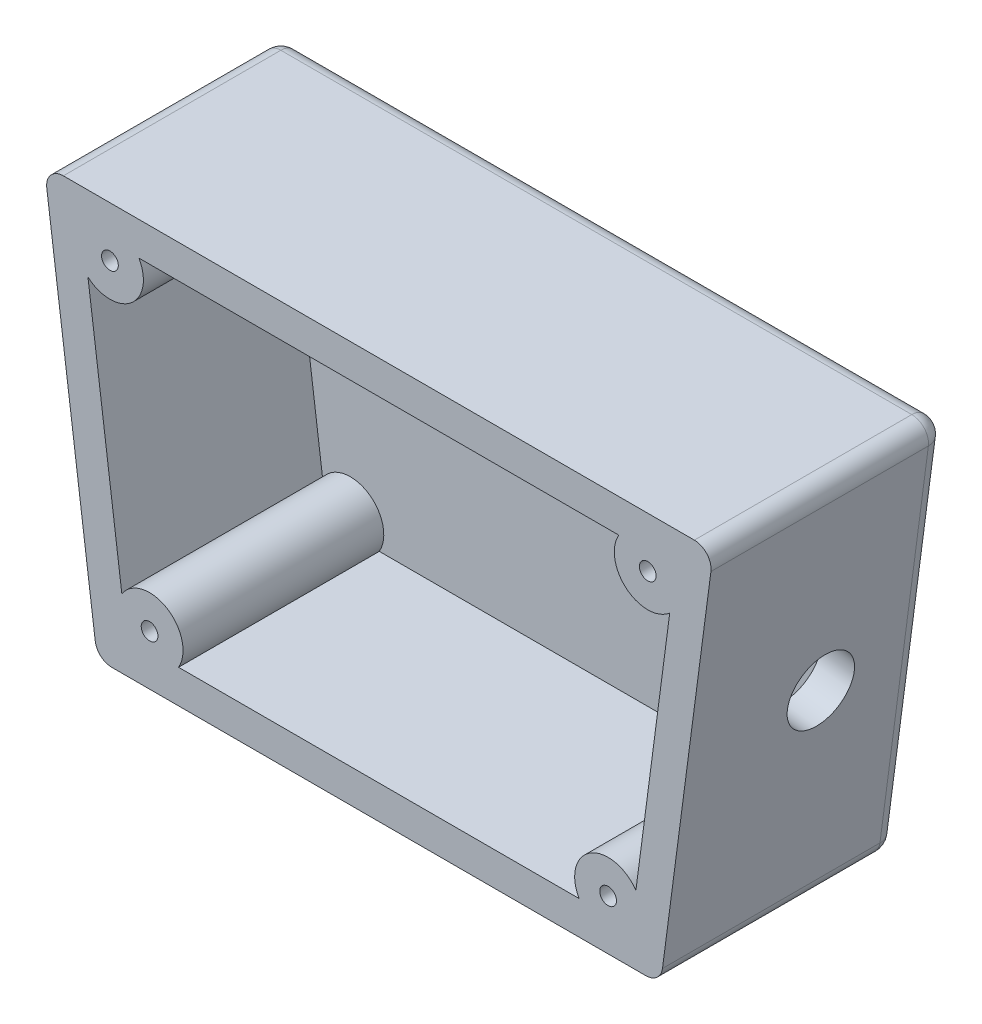
from build123d import *

# Parameters (mm, degrees)
BOSS_EXTRUDE1_DEPTH      = 3.175
BOSS_EXTRUDE2_DEPTH      = 3.175
SKETCH2_R                = 3.175
BOSS_EXTRUDE3_DEPTH      = 6.35
BOSS_EXTRUDE4_DEPTH      = 12.7
SKETCH2_4_R              = 3.175
CUT_EXTRUDE1_DEPTH       = 76.134213245
CUT_EXTRUDE1_DEPTH_BACK  = 76.134213245
FILLET1_R                = 6.35
SKETCH4_R                = 3.175
BOSS_EXTRUDE5_DEPTH      = 6.35
SKETCH4_2_R              = 3.175
CUT_EXTRUDE2_DEPTH       = 76.134213245
CUT_EXTRUDE2_DEPTH_BACK  = 76.134213245
BOSS_EXTRUDE6_DEPTH      = 38.1
BOSS_EXTRUDE7_START      = -38.1
BOSS_EXTRUDE7_DEPTH      = 6.35
BOSS_EXTRUDE11_REACH     = 88.369
SKETCH5_R                = 1.5875
SKETCH5_4_R              = 1.5875
CUT_EXTRUDE9_DEPTH       = 87.36933773
CUT_EXTRUDE9_DEPTH_BACK  = 87.36933773
SKETCH6_R                = 6.35
CUT_EXTRUDE10_DEPTH      = 6.35
CUT_EXTRUDE10_DEPTH_BACK = 510.682305539
CHAMFER1_SIZE            = 2.54
FILLET2_R                = 3.175
FILLET3_R                = 3.175


with BuildPart() as part:
    # Sketch1 → Boss-Extrude1 (new body)
    with BuildSketch(Plane.XY):
        Polygon((-53.468079684, -38.1), (53.468079684, -38.1), (63.5, 38.1), (-63.5, 38.1), align=None)
        Polygon((47.899279144, -31.75), (56.259212741, 31.75), (-56.259212741, 31.75), (-47.899279144, -31.75), align=None, mode=Mode.SUBTRACT)
        Polygon((-47.899279144, -31.75), (47.899279144, -31.75), (56.259212741, 31.75), (-56.259212741, 31.75), align=None)
    extrude(amount=BOSS_EXTRUDE1_DEPTH)

    # Sketch1_3 → Boss-Extrude2 (add)
    with BuildSketch(Plane.XY):
        Polygon((-47.899279144, -31.75), (47.899279144, -31.75), (56.259212741, 31.75), (-56.259212741, 31.75), align=None)
    extrude(amount=-BOSS_EXTRUDE2_DEPTH)

    # Sketch2 → Boss-Extrude3 (add)
    with BuildSketch(Plane.XY):
        with BuildLine():
            ThreePointArc((-37.837241379, 27.272155172), (-39.021250412, 27.544911403), (-39.665603448, 28.575))
            Line((-39.665603448, 28.575), (-39.665603448, 15.875))
            Line((-39.665603448, 15.875), (39.665603448, 15.875))
            Line((39.665603448, 15.875), (39.665603448, 28.575))
            ThreePointArc((39.665603448, 28.575), (39.021250412, 27.544911403), (37.837241379, 27.272155172))
            ThreePointArc((37.837241379, 27.272155172), (0, 30.425258621), (-37.837241379, 27.272155172))
        make_face()
        with Locations((-33.3375, 22.225)):
            Circle(SKETCH2_R, mode=Mode.SUBTRACT)
        with Locations((-23.8125, 22.225)):
            Circle(SKETCH2_R, mode=Mode.SUBTRACT)
        with Locations((-14.2875, 22.225)):
            Circle(SKETCH2_R, mode=Mode.SUBTRACT)
        with Locations((-4.7625, 22.225)):
            Circle(SKETCH2_R, mode=Mode.SUBTRACT)
        with Locations((4.7625, 22.225)):
            Circle(SKETCH2_R, mode=Mode.SUBTRACT)
        with Locations((14.2875, 22.225)):
            Circle(SKETCH2_R, mode=Mode.SUBTRACT)
        with Locations((23.8125, 22.225)):
            Circle(SKETCH2_R, mode=Mode.SUBTRACT)
        with Locations((33.3375, 22.225)):
            Circle(SKETCH2_R, mode=Mode.SUBTRACT)
        with Locations((-33.3375, 22.225)):
            Circle(SKETCH2_R)
        with Locations((-23.8125, 22.225)):
            Circle(SKETCH2_R)
        with Locations((-14.2875, 22.225)):
            Circle(SKETCH2_R)
        with Locations((-4.7625, 22.225)):
            Circle(SKETCH2_R)
        with Locations((4.7625, 22.225)):
            Circle(SKETCH2_R)
        with Locations((14.2875, 22.225)):
            Circle(SKETCH2_R)
        with Locations((23.8125, 22.225)):
            Circle(SKETCH2_R)
        with Locations((33.3375, 22.225)):
            Circle(SKETCH2_R)
        with BuildLine():
            ThreePointArc((-37.837241379, 27.272155172), (0, 30.425258621), (37.837241379, 27.272155172))
            ThreePointArc((37.837241379, 27.272155172), (39.665603448, 28.575), (38.362758621, 30.403362069))
            ThreePointArc((38.362758621, 30.403362069), (0, 33.600258621), (-38.362758621, 30.403362069))
            ThreePointArc((-38.362758621, 30.403362069), (-39.665603448, 28.575), (-37.837241379, 27.272155172))
        make_face()
    extrude(amount=BOSS_EXTRUDE3_DEPTH)

    # Sketch2_3 → Boss-Extrude4 (add)
    with BuildSketch(Plane.XY):
        with BuildLine():
            ThreePointArc((-37.837241379, 27.272155172), (0, 30.425258621), (37.837241379, 27.272155172))
            ThreePointArc((37.837241379, 27.272155172), (39.665603448, 28.575), (38.362758621, 30.403362069))
            ThreePointArc((38.362758621, 30.403362069), (0, 33.600258621), (-38.362758621, 30.403362069))
            ThreePointArc((-38.362758621, 30.403362069), (-39.665603448, 28.575), (-37.837241379, 27.272155172))
        make_face()
    extrude(amount=BOSS_EXTRUDE4_DEPTH)

    # Sketch2_4 → Cut-Extrude1 (cut, two sides)
    with BuildSketch(Plane.XY) as cut_extrude1_sk:
        with Locations((-33.3375, 22.225)):
            Circle(SKETCH2_4_R)
        with Locations((-23.8125, 22.225)):
            Circle(SKETCH2_4_R)
        with Locations((-14.2875, 22.225)):
            Circle(SKETCH2_4_R)
        with Locations((-4.7625, 22.225)):
            Circle(SKETCH2_4_R)
        with Locations((4.7625, 22.225)):
            Circle(SKETCH2_4_R)
        with Locations((14.2875, 22.225)):
            Circle(SKETCH2_4_R)
        with Locations((23.8125, 22.225)):
            Circle(SKETCH2_4_R)
        with Locations((33.3375, 22.225)):
            Circle(SKETCH2_4_R)
    extrude(amount=CUT_EXTRUDE1_DEPTH, mode=Mode.SUBTRACT)
    extrude(cut_extrude1_sk.sketch, amount=-CUT_EXTRUDE1_DEPTH_BACK, mode=Mode.SUBTRACT)

    # Fillet1
    fillet1_edges = [part.edges().sort_by_distance(p)[0] for p in [
        (39.665603448, 15.875, 4.7625),
        (-39.665603448, 15.875, 4.7625),
    ]]
    fillet(fillet1_edges, radius=FILLET1_R)

    # Sketch4 → Boss-Extrude5 (add)
    with BuildSketch(Plane.XY):
        with BuildLine():
            Line((-26.965603448, 6.35), (-26.965603448, -19.05))
            ThreePointArc((-26.965603448, -19.05), (-33.315603448, -25.4), (-39.665603448, -19.05))
            Line((-39.665603448, -19.05), (-39.665603448, 6.35))
            ThreePointArc((-39.665603448, 6.35), (-33.315603448, 12.7), (-26.965603448, 6.35))
        make_face()
        with Locations((-33.315603448, 6.35)):
            Circle(SKETCH4_R, mode=Mode.SUBTRACT)
        with Locations((-33.315603448, -6.35)):
            Circle(SKETCH4_R, mode=Mode.SUBTRACT)
        with Locations((-33.315603448, -19.05)):
            Circle(SKETCH4_R, mode=Mode.SUBTRACT)
        with BuildLine():
            Line((39.665603448, 6.35), (39.665603448, -19.05))
            ThreePointArc((39.665603448, -19.05), (33.315603448, -25.4), (26.965603448, -19.05))
            Line((26.965603448, -19.05), (26.965603448, 6.35))
            ThreePointArc((26.965603448, 6.35), (33.315603448, 12.7), (39.665603448, 6.35))
        make_face()
        with Locations((33.315603448, 6.35)):
            Circle(SKETCH4_R, mode=Mode.SUBTRACT)
        with Locations((33.315603448, -6.35)):
            Circle(SKETCH4_R, mode=Mode.SUBTRACT)
        with Locations((33.315603448, -19.05)):
            Circle(SKETCH4_R, mode=Mode.SUBTRACT)
    extrude(amount=BOSS_EXTRUDE5_DEPTH)

    # Sketch4_2 → Cut-Extrude2 (cut, two sides)
    with BuildSketch(Plane.XY) as cut_extrude2_sk:
        with Locations((-33.315603448, 6.35)):
            Circle(SKETCH4_2_R)
        with Locations((-33.315603448, -6.35)):
            Circle(SKETCH4_2_R)
        with Locations((-33.315603448, -19.05)):
            Circle(SKETCH4_2_R)
        with Locations((33.315603448, -19.05)):
            Circle(SKETCH4_2_R)
        with Locations((33.315603448, -6.35)):
            Circle(SKETCH4_2_R)
        with Locations((33.315603448, 6.35)):
            Circle(SKETCH4_2_R)
    extrude(amount=CUT_EXTRUDE2_DEPTH, mode=Mode.SUBTRACT)
    extrude(cut_extrude2_sk.sketch, amount=-CUT_EXTRUDE2_DEPTH_BACK, mode=Mode.SUBTRACT)

    # Sketch5_4 → Cut-Extrude9 (cut, two sides)
    with BuildSketch(Plane.XY) as cut_extrude9_sk:
        with Locations((-51.037620636, 28.575)):
            Circle(SKETCH5_4_R)
        with Locations((-43.513680399, -28.575)):
            Circle(SKETCH5_4_R)
        with Locations((43.513680399, -28.575)):
            Circle(SKETCH5_4_R)
        with Locations((51.037620636, 28.575)):
            Circle(SKETCH5_4_R)
    extrude(amount=CUT_EXTRUDE9_DEPTH, mode=Mode.SUBTRACT)
    extrude(cut_extrude9_sk.sketch, amount=-CUT_EXTRUDE9_DEPTH_BACK, mode=Mode.SUBTRACT)

    # Chamfer1
    chamfer1_edges = [part.edges().sort_by_distance(p)[0] for p in [
        (-52.625120636, 28.575, 3.175),
        (-45.101180399, -28.575, 3.175),
        (41.926180399, -28.575, 3.175),
        (49.450120636, 28.575, 3.175),
    ]]
    chamfer(chamfer1_edges, length=CHAMFER1_SIZE)

    # Fillet3
    fillet3_edges = [part.edges().sort_by_distance(p)[0] for p in [
        (-53.468079684, -38.1, 1.5875),
        (-63.5, 38.1, 1.5875),
        (63.5, 38.1, 1.5875),
        (53.468079684, -38.1, 1.5875),
    ]]
    fillet(fillet3_edges, radius=FILLET3_R)


with BuildPart() as body_2:
    # Sketch1_4 → Boss-Extrude6 (new body)
    with BuildSketch(Plane.XY):
        Polygon((-53.468079684, -38.1), (53.468079684, -38.1), (63.5, 38.1), (-63.5, 38.1), align=None)
        Polygon((47.899279144, -31.75), (56.259212741, 31.75), (-56.259212741, 31.75), (-47.899279144, -31.75), align=None, mode=Mode.SUBTRACT)
    extrude(amount=-BOSS_EXTRUDE6_DEPTH)

    # Sketch1_5 → Boss-Extrude7 (add)
    with BuildSketch(Plane.XY.offset(BOSS_EXTRUDE7_START)):
        Polygon((-53.468079684, -38.1), (53.468079684, -38.1), (63.5, 38.1), (-63.5, 38.1), align=None)
        Polygon((47.899279144, -31.75), (56.259212741, 31.75), (-56.259212741, 31.75), (-47.899279144, -31.75), align=None, mode=Mode.SUBTRACT)
        Polygon((-47.899279144, -31.75), (47.899279144, -31.75), (56.259212741, 31.75), (-56.259212741, 31.75), align=None)
    extrude(amount=-BOSS_EXTRUDE7_DEPTH)

    # Sketch5 → Boss-Extrude11 (add, up to next)
    with BuildSketch(Plane.XY, mode=Mode.PRIVATE) as boss_extrude11_sk1:
        with BuildLine():
            Line((-56.259212741, 31.75), (-55.211149786, 23.789171499))
            ThreePointArc((-55.211149786, 23.789171499), (-48.408876649, 22.794670853), (-44.687620636, 28.575))
            ThreePointArc((-44.687620636, 28.575), (-44.903991639, 30.218500936), (-45.538359322, 31.75))
            Line((-45.538359322, 31.75), (-56.259212741, 31.75))
        make_face()
        with Locations((-51.037620636, 28.575)):
            Circle(SKETCH5_R, mode=Mode.SUBTRACT)
    boss_extrude11_tool1 = extrude(boss_extrude11_sk1.sketch, amount=-BOSS_EXTRUDE11_REACH, mode=Mode.PRIVATE) - body_2.part
    # Sketch5 → Boss-Extrude11 (add, up to next)
    with BuildSketch(Plane.XY, mode=Mode.PRIVATE) as boss_extrude11_sk2:
        with BuildLine():
            Line((-48.783663554, -25.03243348), (-47.899279144, -31.75))
            Line((-47.899279144, -31.75), (-38.014419085, -31.75))
            ThreePointArc((-38.014419085, -31.75), (-37.380051402, -30.218500936), (-37.163680399, -28.575))
            ThreePointArc((-37.163680399, -28.575), (-41.661910034, -22.501002427), (-48.783663554, -25.03243348))
        make_face()
        with Locations((-43.513680399, -28.575)):
            Circle(SKETCH5_R, mode=Mode.SUBTRACT)
    boss_extrude11_tool2 = extrude(boss_extrude11_sk2.sketch, amount=-BOSS_EXTRUDE11_REACH, mode=Mode.PRIVATE) - body_2.part
    # Sketch5 → Boss-Extrude11 (add, up to next)
    with BuildSketch(Plane.XY, mode=Mode.PRIVATE) as boss_extrude11_sk3:
        with BuildLine():
            ThreePointArc((48.783663554, -25.03243348), (40.152941328, -23.187242313), (38.014419085, -31.75))
            Line((38.014419085, -31.75), (47.899279144, -31.75))
            Line((47.899279144, -31.75), (48.783663554, -25.03243348))
        make_face()
        with Locations((43.513680399, -28.575)):
            Circle(SKETCH5_R, mode=Mode.SUBTRACT)
    boss_extrude11_tool3 = extrude(boss_extrude11_sk3.sketch, amount=-BOSS_EXTRUDE11_REACH, mode=Mode.PRIVATE) - body_2.part
    # Sketch5 → Boss-Extrude11 (add, up to next)
    with BuildSketch(Plane.XY, mode=Mode.PRIVATE) as boss_extrude11_sk4:
        with BuildLine():
            ThreePointArc((45.538359322, 31.75), (47.002389658, 23.671999801), (55.211149786, 23.789171499))
            Line((55.211149786, 23.789171499), (56.259212741, 31.75))
            Line((56.259212741, 31.75), (45.538359322, 31.75))
        make_face()
        with Locations((51.037620636, 28.575)):
            Circle(SKETCH5_R, mode=Mode.SUBTRACT)
    boss_extrude11_tool4 = extrude(boss_extrude11_sk4.sketch, amount=-BOSS_EXTRUDE11_REACH, mode=Mode.PRIVATE) - body_2.part
    add(boss_extrude11_tool1.solids().sort_by_distance((-48.470922, 22.931101, 0))[0])
    add(boss_extrude11_tool2.solids().sort_by_distance((-48.192507, -28.371605, 0))[0])
    add(boss_extrude11_tool3.solids().sort_by_distance((40.232461, -23.314724, 0))[0])
    add(boss_extrude11_tool4.solids().sort_by_distance((47.097631, 23.787723, 0))[0])

    # Sketch6 → Cut-Extrude10 (cut, two sides)
    with BuildSketch(Plane(origin=(-2.773412859, -465.296548287, 0), x_dir=(0, 0, -1), z_dir=(-0.9914448613738105, 0.1305261922200517, 0))) as cut_extrude10_sk:
        with Locations(Location((25.4, -469.31157386, 0), (0, 0, 90))):
            Circle(SKETCH6_R)
    extrude(amount=CUT_EXTRUDE10_DEPTH, mode=Mode.SUBTRACT)
    extrude(cut_extrude10_sk.sketch, amount=-CUT_EXTRUDE10_DEPTH_BACK, mode=Mode.SUBTRACT)

    # Fillet2
    fillet2_edges = [body_2.edges().sort_by_distance(p)[0] for p in [
        (-53.468079684, -38.1, -22.225),
        (-63.5, 38.1, -22.225),
        (63.5, 38.1, -22.225),
        (53.468079684, -38.1, -22.225),
        (0, -38.1, -44.45),
        (58.484039842, 0, -44.45),
        (-58.484039842, 0, -44.45),
        (0, 38.1, -44.45),
    ]]
    fillet(fillet2_edges, radius=FILLET2_R)


solid = body_2.part
